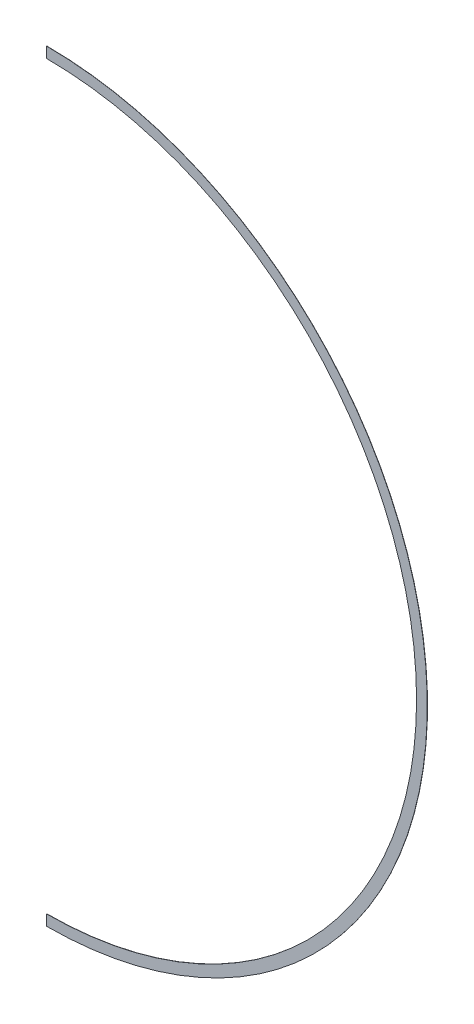
from build123d import *

# Parameters (mm, degrees)
BOSS_EXTRUDE1_DEPTH = 0.127
SKETCH2_W           = 0.25
SKETCH2_H           = 426
CUT_EXTRUDE1_DEPTH  = 1.127


with BuildPart() as part:
    # Sketch1 → Boss-Extrude1 (new body)
    with BuildSketch(Plane.XY):
        with BuildLine():
            Line((0, 213), (0, 207))
            ThreePointArc((0, 207), (207, 0), (0, -207))
            Line((0, -207), (0, -213))
            ThreePointArc((0, -213), (213, 0), (0, 213))
        make_face()
    extrude(amount=BOSS_EXTRUDE1_DEPTH)

    # Sketch2 → Cut-Extrude1 (cut, through all)
    with BuildSketch(Plane.XY.offset(0.127)):
        with Locations((0.125, 0)):
            Rectangle(SKETCH2_W, SKETCH2_H)
    extrude(amount=-CUT_EXTRUDE1_DEPTH, mode=Mode.SUBTRACT)


solid = part.part
